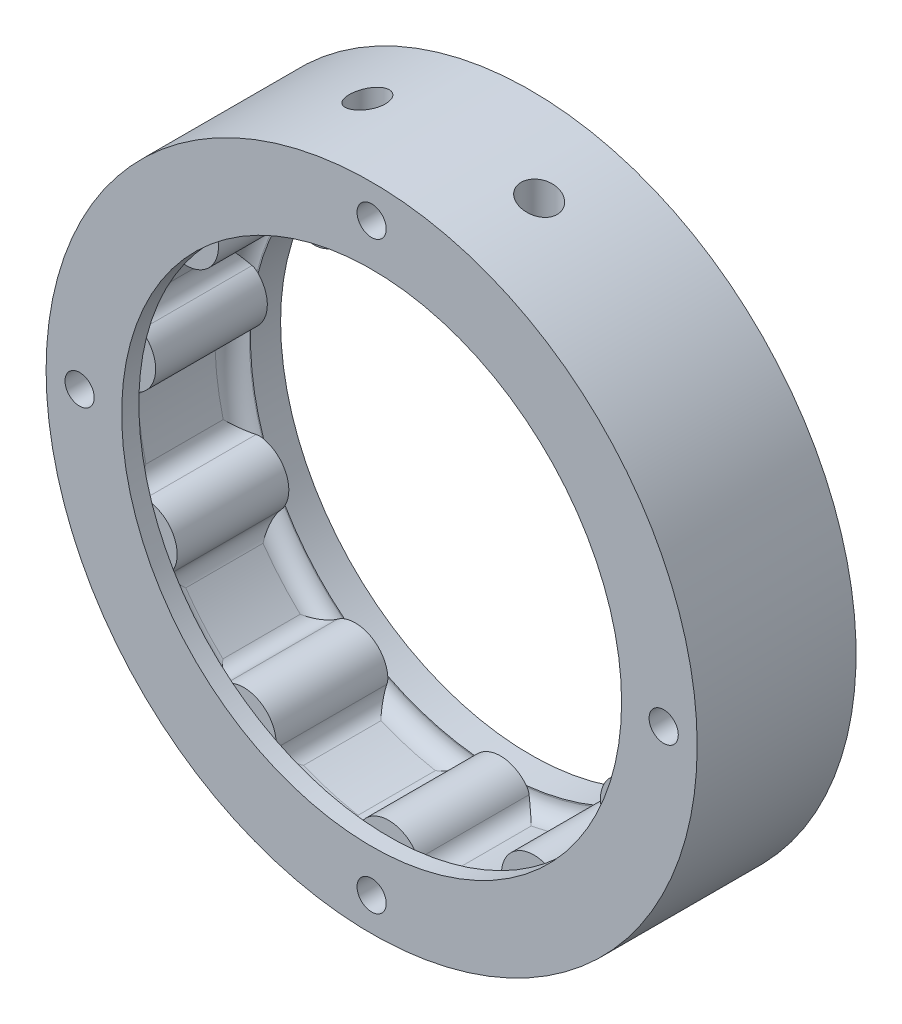
from build123d import *

# Parameters (mm, degrees)
SKETCH_1_R          = 37.9
SKETCH_1_R_2        = 1.7
EXTRUDE_1_DEPTH     = 13
SKETCH_2_R          = 37.9
SKETCH_2_R_2        = 29.1
EXTRUDE_2_DEPTH     = 3.5
SKETCH_3_R          = 37.9
SKETCH_3_R_2        = 29.1
EXTRUDE_3_DEPTH     = 2
FILLET_1_R          = 2
SKETCH_4_R          = 1.7
CUT_EXTRUDE_3_DEPTH = 21
SKETCH_6_R          = 2.1
CUT_EXTRUDE_4_DEPTH = 6.5
SKETCH_7_R          = 2.1
CUT_EXTRUDE_6_DEPTH = 6.5


with BuildPart() as part:
    # 草图1 → 凸台-拉伸1 (new body)
    with BuildSketch(Plane.XY):
        Circle(SKETCH_1_R)
        with Locations((0, -34)):
            Circle(SKETCH_1_R_2, mode=Mode.SUBTRACT)
        with Locations((-34, 0)):
            Circle(SKETCH_1_R_2, mode=Mode.SUBTRACT)
        with Locations((0, 34)):
            Circle(SKETCH_1_R_2, mode=Mode.SUBTRACT)
        with Locations((34, 0)):
            Circle(SKETCH_1_R_2, mode=Mode.SUBTRACT)
        with BuildLine():
            ThreePointArc((-31.233783039, 0.679693363), (-30.923187588, -4.446083156), (-29.777103616, -9.451734562))
            ThreePointArc((-29.777103616, -9.451734562), (-24.98031659, -11.408128335), (-26.643000301, -16.314463551))
            ThreePointArc((-26.643000301, -16.314463551), (-23.610506772, -20.458620578), (-19.940100115, -24.050022732))
            ThreePointArc((-19.940100115, -24.050022732), (-14.847079754, -23.102507047), (-13.593253218, -28.128893561))
            ThreePointArc((-13.593253218, -28.128893561), (-8.801656881, -29.97569052), (-3.772255717, -31.012598614))
            ThreePointArc((-3.772255717, -31.012598614), (0, -27.462003005), (3.772255717, -31.012598614))
            ThreePointArc((3.772255717, -31.012598614), (8.801656881, -29.97569052), (13.593253218, -28.128893561))
            ThreePointArc((13.593253218, -28.128893561), (14.847079754, -23.102507047), (19.940100115, -24.050022732))
            ThreePointArc((19.940100115, -24.050022732), (23.610506772, -20.458620578), (26.643000301, -16.314463551))
            ThreePointArc((26.643000301, -16.314463551), (24.98031659, -11.408128335), (29.777103616, -9.451734562))
            ThreePointArc((29.777103616, -9.451734562), (30.923187588, -4.446083156), (31.233783039, 0.679693363))
            ThreePointArc((31.233783039, 0.679693363), (27.182479412, 3.908250516), (30.160087115, 8.147412549))
            ThreePointArc((30.160087115, 8.147412549), (28.417974836, 12.978054253), (25.90806035, 17.458052438))
            ThreePointArc((25.90806035, 17.458052438), (20.754397082, 17.983787444), (20.967456055, 23.159813742))
            ThreePointArc((20.967456055, 23.159813742), (16.890255867, 26.281751136), (12.356711557, 28.693603216))
            ThreePointArc((12.356711557, 28.693603216), (7.736940323, 26.349598925), (5.117805847, 30.819137712))
            ThreePointArc((5.117805847, 30.819137712), (0, 31.241177731), (-5.117805847, 30.819137712))
            ThreePointArc((-5.117805847, 30.819137712), (-7.736940323, 26.349598925), (-12.356711557, 28.693603216))
            ThreePointArc((-12.356711557, 28.693603216), (-16.890255867, 26.281751136), (-20.967456055, 23.159813742))
            ThreePointArc((-20.967456055, 23.159813742), (-20.754397082, 17.983787444), (-25.90806035, 17.458052438))
            ThreePointArc((-25.90806035, 17.458052438), (-28.417974836, 12.978054253), (-30.160087115, 8.147412549))
            ThreePointArc((-30.160087115, 8.147412549), (-27.182479412, 3.908250516), (-31.233783039, 0.679693363))
        make_face(mode=Mode.SUBTRACT)
    extrude(amount=EXTRUDE_1_DEPTH)

    # 草图2 → 凸台-拉伸2 (add)
    with BuildSketch(Plane(origin=(0, 0, 0), x_dir=(-1, 0, 0), z_dir=(0, 0, -1))):
        Circle(SKETCH_2_R)
        Circle(SKETCH_2_R_2, mode=Mode.SUBTRACT)
    extrude(amount=EXTRUDE_2_DEPTH)

    # 草图3 → 凸台-拉伸3 (add)
    with BuildSketch(Plane.XY.offset(13)):
        Circle(SKETCH_3_R)
        Circle(SKETCH_3_R_2, mode=Mode.SUBTRACT)
    extrude(amount=EXTRUDE_3_DEPTH)

    # 圆角1
    fillet_1_edges = [part.edges().sort_by_distance(p)[0] for p in [
        (-16.890255867, 26.281751136, 0),
        (-12.356711557, 28.693603216, 6.5),
        (-20.967456055, 23.159813742, 6.5),
        (-28.417974836, 12.978054253, 0),
        (-25.90806035, 17.458052438, 6.5),
        (-30.160087115, 8.147412549, 6.5),
        (-30.923187588, -4.446083156, 0),
        (-31.233783039, 0.679693363, 6.5),
        (-29.777103616, -9.451734562, 6.5),
        (-23.610506772, -20.458620578, 0),
        (-26.643000301, -16.314463551, 6.5),
        (-19.940100115, -24.050022732, 6.5),
        (-8.801656881, -29.97569052, 0),
        (-13.593253218, -28.128893561, 6.5),
        (-3.772255717, -31.012598614, 6.5),
        (8.801656881, -29.97569052, 0),
        (3.772255717, -31.012598614, 6.5),
        (13.593253218, -28.128893561, 6.5),
        (23.610506772, -20.458620578, 0),
        (19.940100115, -24.050022732, 6.5),
        (26.643000301, -16.314463551, 6.5),
        (30.923187588, -4.446083156, 0),
        (29.777103616, -9.451734562, 6.5),
        (31.233783039, 0.679693363, 6.5),
        (28.417974836, 12.978054253, 0),
        (30.160087115, 8.147412549, 6.5),
        (25.90806035, 17.458052438, 6.5),
        (16.890255867, 26.281751136, 0),
        (20.967456055, 23.159813742, 6.5),
        (12.356711557, 28.693603216, 6.5),
        (0, 31.241177731, 0),
        (5.117805847, 30.819137712, 6.5),
        (-5.117805847, 30.819137712, 6.5),
        (-16.890255867, 26.281751136, 13),
        (-28.417974836, 12.978054253, 13),
        (-30.923187588, -4.446083156, 13),
        (-23.610506772, -20.458620578, 13),
        (-8.801656881, -29.97569052, 13),
        (8.801656881, -29.97569052, 13),
        (23.610506772, -20.458620578, 13),
        (30.923187588, -4.446083156, 13),
        (28.417974836, 12.978054253, 13),
        (16.890255867, 26.281751136, 13),
        (0, 31.241177731, 13),
    ]]
    fillet(fillet_1_edges, radius=FILLET_1_R)

    # 草图4 → 切除-拉伸3 (cut)
    with BuildSketch(Plane(origin=(0, 0, -3.5), x_dir=(-1, 0, 0), z_dir=(0, 0, -1))):
        with Locations((0, -34)):
            Circle(SKETCH_4_R)
        with Locations((-34, 0)):
            Circle(SKETCH_4_R)
        with Locations((0, 34)):
            Circle(SKETCH_4_R)
        with Locations((34, 0)):
            Circle(SKETCH_4_R)
    extrude(amount=-CUT_EXTRUDE_3_DEPTH, mode=Mode.SUBTRACT)

    # 草图6 → 切除-拉伸4 (cut)
    with BuildSketch(Plane(origin=(0, 38, 0), x_dir=(1, 0, 0), z_dir=(0, 1, 0))):
        with Locations((-10, -5.5)):
            Circle(SKETCH_6_R)
        with Locations((10, -5.5)):
            Circle(SKETCH_6_R)
    extrude(amount=-CUT_EXTRUDE_4_DEPTH, mode=Mode.SUBTRACT)

    # 草图7 → 切除-拉伸6 (cut)
    with BuildSketch(Plane(origin=(0, -38, 0), x_dir=(1, 0, 0), z_dir=(0, 1, 0))):
        with Locations((-10, -5.5)):
            Circle(SKETCH_7_R)
        with Locations((10, -5.5)):
            Circle(SKETCH_7_R)
    extrude(amount=CUT_EXTRUDE_6_DEPTH, mode=Mode.SUBTRACT)


solid = part.part
